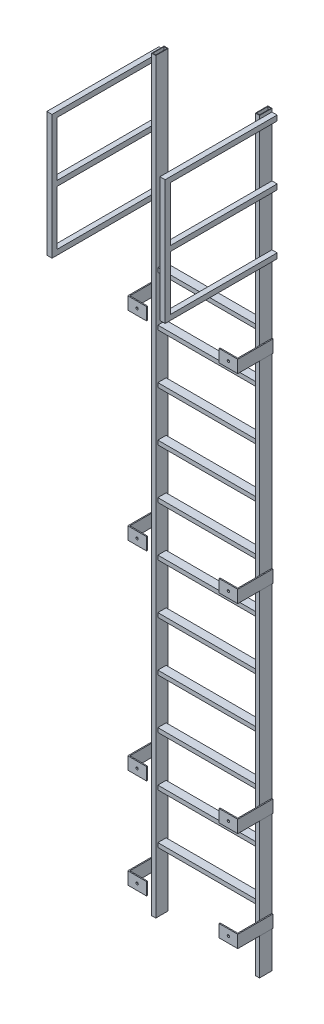
from build123d import *

# Parameters (mm, degrees)
SKETCH1_W             = 25.4
SKETCH1_H             = 4572
BOSS_EXTRUDE1_DEPTH   = 38.1
BOSS_EXTRUDE1_2_DEPTH = 38.1
SKETCH2_W             = 19.05
SKETCH2_H             = 69.85
CUT_EXTRUDE1_DEPTH    = 4572
SKETCH3_W             = 50.8
SKETCH3_H             = 25.4
SKETCH3_W_2           = 38.1
SKETCH3_H_2           = 12.7
BOSS_EXTRUDE2_DEPTH   = 609.6
LPATTERN1_COUNT       = 11
LPATTERN1_PITCH       = 304.8
BOSS_EXTRUDE3_START   = -1219.2
BOSS_EXTRUDE3_DEPTH   = 76.2
SKETCH5_R             = 7.14375
CUT_EXTRUDE2_DEPTH    = 6.35
LPATTERN2_COUNT       = 3
LPATTERN2_PITCH       = 1219.2
LPATTERN3_COUNT       = 2
LPATTERN3_PITCH       = 3048
SKETCH8_W             = 31.75
SKETCH8_H             = 31.75
BOSS_EXTRUDE4_DEPTH   = 685.8
SKETCH9_W             = 31.75
SKETCH9_H             = 762.254
BOSS_EXTRUDE5_DEPTH   = 31.75


with BuildPart() as part:
    # Sketch1 → Boss-Extrude1 (new body, symmetric)
    with BuildSketch(Plane.XY):
        with Locations((317.5, -2286)):
            Rectangle(SKETCH1_W, SKETCH1_H)
    extrude(amount=BOSS_EXTRUDE1_DEPTH, both=True)


with BuildPart() as body_2:
    # Sketch1 → Boss-Extrude1 2 (new body, symmetric)
    with BuildSketch(Plane.XY):
        with Locations((-317.5, -2286)):
            Rectangle(SKETCH1_W, SKETCH1_H)
    extrude(amount=BOSS_EXTRUDE1_2_DEPTH, both=True)


with BuildPart() as cut_extrude1_tool:
    # Sketch2 → Cut-Extrude1 (new body)
    with BuildSketch(Plane(origin=(0, 0, 0), x_dir=(1, 0, 0), z_dir=(0, 1, 0))):
        with Locations((-317.5, 0)):
            Rectangle(SKETCH2_W, SKETCH2_H)
        with Locations((317.5, 0)):
            Rectangle(SKETCH2_W, SKETCH2_H)
    extrude(amount=-CUT_EXTRUDE1_DEPTH)


with BuildPart() as part_1:
    add(part.part)

    # Cut-Extrude1: cut by cut_extrude1_tool
    add(cut_extrude1_tool.part, mode=Mode.SUBTRACT)



with BuildPart() as body_2_1:
    add(body_2.part)

    # Cut-Extrude1: cut by cut_extrude1_tool
    add(cut_extrude1_tool.part, mode=Mode.SUBTRACT)


with BuildPart() as part_2:
    add(part_1.part)

    add(body_2_1.part)  # Boss-Extrude2 merges body 2
    # Sketch3 → Boss-Extrude2 (add)
    with BuildSketch(Plane.ZY.offset(-304.8)):
        with Locations((0, -1143)):
            Rectangle(SKETCH3_W, SKETCH3_H)
        with Locations((0, -1143)):
            Rectangle(SKETCH3_W_2, SKETCH3_H_2, mode=Mode.SUBTRACT)
    boss_extrude2 = extrude(amount=BOSS_EXTRUDE2_DEPTH)

    # LPattern1: Boss-Extrude2 ×11
    with Locations(*[(0, -i * LPATTERN1_PITCH, 0) for i in range(1, LPATTERN1_COUNT)]):
        add(boss_extrude2)

    # Sketch4 → Boss-Extrude3 (add)
    with BuildSketch(Plane(origin=(0, 0, 0), x_dir=(1, 0, 0), z_dir=(0, 1, 0)).offset(BOSS_EXTRUDE3_START)):
        Polygon((330.2, 38.1), (336.55, 38.1), (336.55, -177.8), (222.25, -177.8), (222.25, -171.45), (330.2, -171.45), align=None)
        Polygon((-330.2, -171.45), (-330.2, 38.1), (-336.55, 38.1), (-336.55, -177.8), (-222.25, -177.8), (-222.25, -171.45), align=None)
    boss_extrude3 = extrude(amount=-BOSS_EXTRUDE3_DEPTH)

    # Sketch5 → Cut-Extrude2 (cut)
    with BuildSketch(Plane.XY.offset(177.8)):
        with Locations((-279.4, -1257.3)):
            Circle(SKETCH5_R)
        with Locations((279.4, -1257.3)):
            Circle(SKETCH5_R)
    cut_extrude2 = extrude(amount=-CUT_EXTRUDE2_DEPTH, mode=Mode.SUBTRACT)

    # LPattern2: Boss-Extrude3, Cut-Extrude2 ×3
    with Locations(*[(0, -i * LPATTERN2_PITCH, 0) for i in range(1, LPATTERN2_COUNT)]):
        add(boss_extrude3)
        add(cut_extrude2, mode=Mode.SUBTRACT)

    # LPattern3: Boss-Extrude3, Cut-Extrude2 ×2
    with Locations(*[(0, -i * LPATTERN3_PITCH, 0) for i in range(1, LPATTERN3_COUNT)]):
        add(boss_extrude3)
        add(cut_extrude2, mode=Mode.SUBTRACT)

    # Sketch8 → Boss-Extrude4 (add)
    with BuildSketch(Plane(origin=(0, 0, -38.1), x_dir=(-1, 0, 0), z_dir=(0, 0, -1))):
        with Locations((-346.075, -35.610098765)):
            Rectangle(SKETCH8_W, SKETCH8_H)
        with Locations((-346.075, -400.862098765)):
            Rectangle(SKETCH8_W, SKETCH8_H)
        with Locations((-346.075, -766.114098765)):
            Rectangle(SKETCH8_W, SKETCH8_H)
        with Locations((346.075, -766.114098765)):
            Rectangle(SKETCH8_W, SKETCH8_H)
        with Locations((346.075, -400.862098765)):
            Rectangle(SKETCH8_W, SKETCH8_H)
        with Locations((346.075, -35.610098765)):
            Rectangle(SKETCH8_W, SKETCH8_H)
    extrude(amount=-BOSS_EXTRUDE4_DEPTH)

    # Sketch9 → Boss-Extrude5 (add)
    with BuildSketch(Plane.XY.offset(647.7)):
        with Locations((-346.075, -400.862098765)):
            Rectangle(SKETCH9_W, SKETCH9_H)
        with Locations((346.075, -400.862098765)):
            Rectangle(SKETCH9_W, SKETCH9_H)
    extrude(amount=-BOSS_EXTRUDE5_DEPTH)


solid = part_2.part
